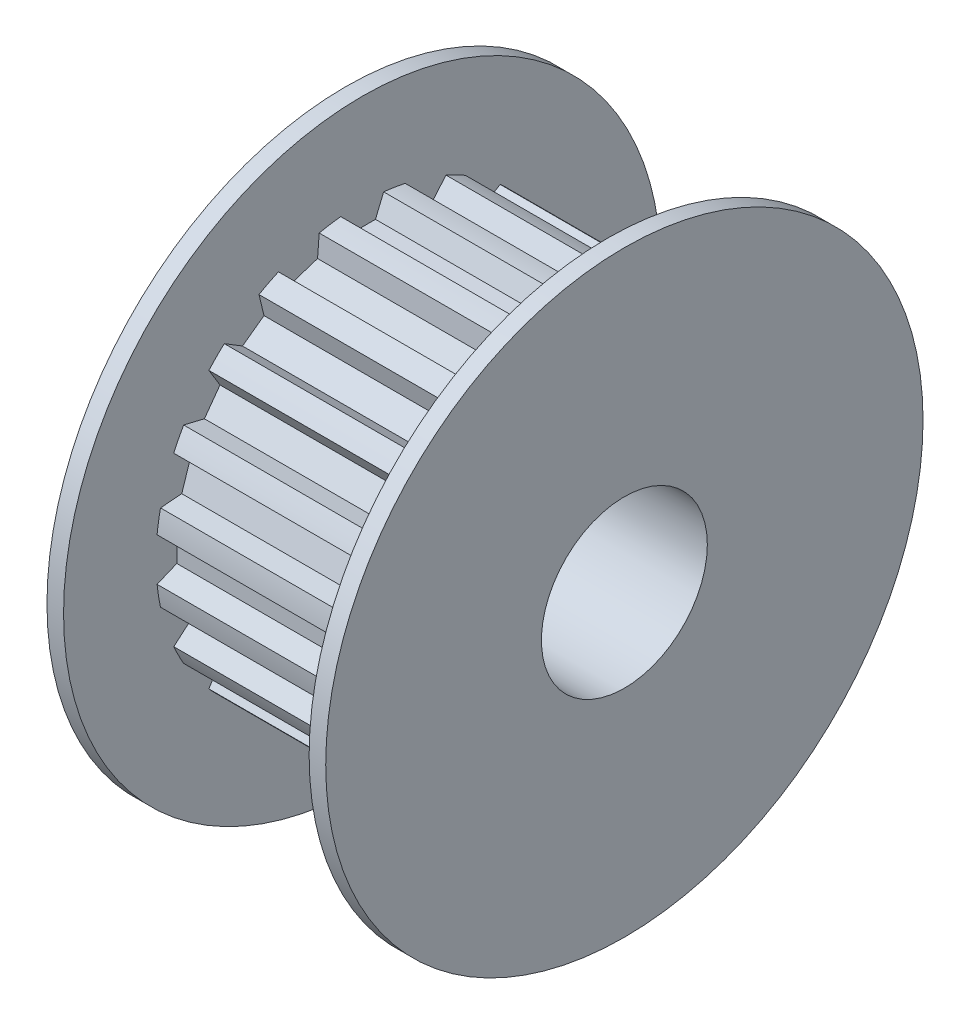
from build123d import *

# Parameters (mm, degrees)
SKETCH1_W                    = 0.5
SKETCH1_H                    = 9
BOSS_EXTRUDE1_DEPTH          = 7.4
SKETCH3_R                    = 9
BOSS_EXTRUDE2_DEPTH          = 0.5
F_5_0_5_DIAMETER_HOLE1_D     = 5
F_5_0_5_DIAMETER_HOLE1_DEPTH = 8.4


with BuildPart() as part:
    # Sketch1 → Revolve1 (revolve)
    with BuildSketch(Plane(origin=(0, 0, 0), x_dir=(-1, 0, 0), z_dir=(0, 0, -1))):
        with Locations((-7.65, 4.5)):
            Rectangle(SKETCH1_W, SKETCH1_H)
    revolve(axis=Axis((7.9, 0, 0), (-1, 0, 0)))

    # Sketch2 → Boss-Extrude1 (add)
    with BuildSketch(Plane.ZY.offset(-7.4)):
        with BuildLine():
            Line((6.078441347, -1.295675803), (5.437383609, -1.346128141))
            Line((5.437383609, -1.346128141), (5.190170014, -2.106973354))
            Line((5.190170014, -2.106973354), (5.679141478, -2.524594437))
            ThreePointArc((5.679141478, -2.524594437), (5.537605548, -2.821550956), (5.38055541, -3.110602591))
            Line((5.38055541, -3.110602591), (4.755282641, -2.96048788))
            Line((4.755282641, -2.96048788), (4.285054439, -3.607701476))
            Line((4.285054439, -3.607701476), (4.621041925, -4.155983221))
            ThreePointArc((4.621041925, -4.155983221), (4.394668645, -4.394668645), (4.155983221, -4.621041925))
            Line((4.155983221, -4.621041925), (3.607701476, -4.285054439))
            Line((3.607701476, -4.285054439), (2.96048788, -4.755282641))
            Line((2.96048788, -4.755282641), (3.110602591, -5.38055541))
            ThreePointArc((3.110602591, -5.38055541), (2.821550956, -5.537605548), (2.524594437, -5.679141478))
            Line((2.524594437, -5.679141478), (2.106973354, -5.190170014))
            Line((2.106973354, -5.190170014), (1.346128141, -5.437383609))
            Line((1.346128141, -5.437383609), (1.295675803, -6.078441347))
            ThreePointArc((1.295675803, -6.078441347), (0.9722402, -6.138483037), (0.64608076, -6.181327095))
            Line((0.64608076, -6.181327095), (0.4, -5.587235585))
            Line((0.4, -5.587235585), (-0.4, -5.587235585))
            Line((-0.4, -5.587235585), (-0.64608076, -6.181327095))
            ThreePointArc((-0.64608076, -6.181327095), (-0.9722402, -6.138483037), (-1.295675803, -6.078441347))
            Line((-1.295675803, -6.078441347), (-1.346128141, -5.437383609))
            Line((-1.346128141, -5.437383609), (-2.106973354, -5.190170014))
            Line((-2.106973354, -5.190170014), (-2.524594437, -5.679141478))
            ThreePointArc((-2.524594437, -5.679141478), (-2.821550956, -5.537605548), (-3.110602591, -5.38055541))
            Line((-3.110602591, -5.38055541), (-2.96048788, -4.755282641))
            Line((-2.96048788, -4.755282641), (-3.607701476, -4.285054439))
            Line((-3.607701476, -4.285054439), (-4.155983221, -4.621041925))
            ThreePointArc((-4.155983221, -4.621041925), (-4.394668645, -4.394668645), (-4.621041925, -4.155983221))
            Line((-4.621041925, -4.155983221), (-4.285054439, -3.607701476))
            Line((-4.285054439, -3.607701476), (-4.755282641, -2.96048788))
            Line((-4.755282641, -2.96048788), (-5.38055541, -3.110602591))
            ThreePointArc((-5.38055541, -3.110602591), (-5.537605548, -2.821550956), (-5.679141478, -2.524594437))
            Line((-5.679141478, -2.524594437), (-5.190170014, -2.106973354))
            Line((-5.190170014, -2.106973354), (-5.437383609, -1.346128141))
            Line((-5.437383609, -1.346128141), (-6.078441347, -1.295675803))
            ThreePointArc((-6.078441347, -1.295675803), (-6.138483037, -0.9722402), (-6.181327095, -0.64608076))
            Line((-6.181327095, -0.64608076), (-5.587235585, -0.4))
            Line((-5.587235585, -0.4), (-5.587235585, 0.4))
            Line((-5.587235585, 0.4), (-6.181327095, 0.64608076))
            ThreePointArc((-6.181327095, 0.64608076), (-6.138483037, 0.9722402), (-6.078441347, 1.295675803))
            Line((-6.078441347, 1.295675803), (-5.437383609, 1.346128141))
            Line((-5.437383609, 1.346128141), (-5.190170014, 2.106973354))
            Line((-5.190170014, 2.106973354), (-5.679141478, 2.524594437))
            ThreePointArc((-5.679141478, 2.524594437), (-5.537605548, 2.821550956), (-5.38055541, 3.110602591))
            Line((-5.38055541, 3.110602591), (-4.755282641, 2.96048788))
            Line((-4.755282641, 2.96048788), (-4.285054439, 3.607701476))
            Line((-4.285054439, 3.607701476), (-4.621041925, 4.155983221))
            ThreePointArc((-4.621041925, 4.155983221), (-4.394668645, 4.394668645), (-4.155983221, 4.621041925))
            Line((-4.155983221, 4.621041925), (-3.607701476, 4.285054439))
            Line((-3.607701476, 4.285054439), (-2.96048788, 4.755282641))
            Line((-2.96048788, 4.755282641), (-3.110602591, 5.38055541))
            ThreePointArc((-3.110602591, 5.38055541), (-2.821550956, 5.537605548), (-2.524594437, 5.679141478))
            Line((-2.524594437, 5.679141478), (-2.106973354, 5.190170014))
            Line((-2.106973354, 5.190170014), (-1.346128141, 5.437383609))
            Line((-1.346128141, 5.437383609), (-1.295675803, 6.078441347))
            ThreePointArc((-1.295675803, 6.078441347), (-0.9722402, 6.138483037), (-0.64608076, 6.181327095))
            Line((-0.64608076, 6.181327095), (-0.4, 5.587235585))
            Line((-0.4, 5.587235585), (0.4, 5.587235585))
            Line((0.4, 5.587235585), (0.64608076, 6.181327095))
            ThreePointArc((0.64608076, 6.181327095), (0.9722402, 6.138483037), (1.295675803, 6.078441347))
            Line((1.295675803, 6.078441347), (1.346128141, 5.437383609))
            Line((1.346128141, 5.437383609), (2.106973354, 5.190170014))
            Line((2.106973354, 5.190170014), (2.524594437, 5.679141478))
            ThreePointArc((2.524594437, 5.679141478), (2.821550956, 5.537605548), (3.110602591, 5.38055541))
            Line((3.110602591, 5.38055541), (2.96048788, 4.755282641))
            Line((2.96048788, 4.755282641), (3.607701476, 4.285054439))
            Line((3.607701476, 4.285054439), (4.155983221, 4.621041925))
            ThreePointArc((4.155983221, 4.621041925), (4.394668645, 4.394668645), (4.621041925, 4.155983221))
            Line((4.621041925, 4.155983221), (4.285054439, 3.607701476))
            Line((4.285054439, 3.607701476), (4.755282641, 2.96048788))
            Line((4.755282641, 2.96048788), (5.38055541, 3.110602591))
            ThreePointArc((5.38055541, 3.110602591), (5.537605548, 2.821550956), (5.679141478, 2.524594437))
            Line((5.679141478, 2.524594437), (5.190170014, 2.106973354))
            Line((5.190170014, 2.106973354), (5.437383609, 1.346128141))
            Line((5.437383609, 1.346128141), (6.078441347, 1.295675803))
            ThreePointArc((6.078441347, 1.295675803), (6.138483037, 0.9722402), (6.181327095, 0.64608076))
            Line((6.181327095, 0.64608076), (5.587235585, 0.4))
            Line((5.587235585, 0.4), (5.587235585, -0.4))
            Line((5.587235585, -0.4), (6.181327095, -0.64608076))
            ThreePointArc((6.181327095, -0.64608076), (6.138483037, -0.9722402), (6.078441347, -1.295675803))
        make_face()
    extrude(amount=BOSS_EXTRUDE1_DEPTH)

    # Sketch3 → Boss-Extrude2 (add)
    with BuildSketch(Plane(origin=(0, 0, 0), x_dir=(0, 0, -1), z_dir=(1, 0, 0))):
        Circle(SKETCH3_R)
    extrude(amount=-BOSS_EXTRUDE2_DEPTH)

    # Ø5.0 (5) Diameter Hole1
    with Locations(Plane(origin=(7.9, 0, 0), x_dir=(0, 0, -1), z_dir=(1, 0, 0))):
        with Locations((0, 0)):
            Hole(F_5_0_5_DIAMETER_HOLE1_D / 2, depth=F_5_0_5_DIAMETER_HOLE1_DEPTH)


solid = part.part
